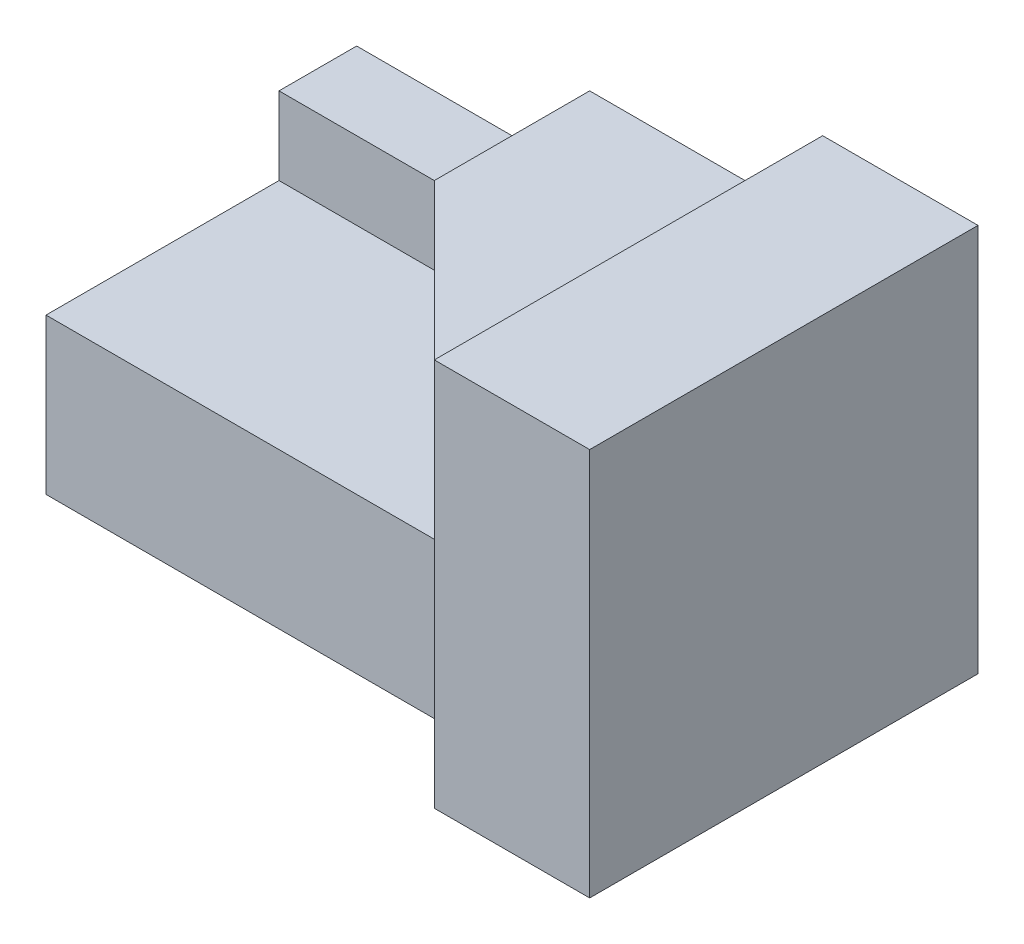
from build123d import *

# Parameters (mm, degrees)
SKETCH1_W           = 80
SKETCH1_H           = 50
BOSS_EXTRUDE2_DEPTH = 50
SKETCH2_W           = 60
SKETCH2_H           = 10
CUT_EXTRUDE1_DEPTH  = 50
SKETCH3_W           = 30
SKETCH3_H           = 10
CUT_EXTRUDE2_DEPTH  = 50
CUT_EXTRUDE3_DEPTH  = 50
CUT_EXTRUDE4_DEPTH  = 20
CUT_EXTRUDE5_DEPTH  = 10


with BuildPart() as part:
    # Sketch1 → Boss-Extrude2 (new body)
    with BuildSketch(Plane.XY):
        with Locations((40, 25)):
            Rectangle(SKETCH1_W, SKETCH1_H)
    extrude(amount=-BOSS_EXTRUDE2_DEPTH)

    # Sketch2 → Cut-Extrude1 (cut)
    with BuildSketch(Plane.XY):
        with Locations((30, 45)):
            Rectangle(SKETCH2_W, SKETCH2_H)
    extrude(amount=-CUT_EXTRUDE1_DEPTH, mode=Mode.SUBTRACT)

    # Sketch3 → Cut-Extrude2 (cut)
    with BuildSketch(Plane.XY):
        with Locations((15, 35)):
            Rectangle(SKETCH3_W, SKETCH3_H)
    extrude(amount=-CUT_EXTRUDE2_DEPTH, mode=Mode.SUBTRACT)

    # Sketch4 → Cut-Extrude3 (cut)
    with BuildSketch(Plane.XZ):
        Polygon((60, 0), (0, 0), (0, -10), (50, -10), align=None)
    extrude(amount=-CUT_EXTRUDE3_DEPTH, mode=Mode.SUBTRACT)

    # Sketch5 → Cut-Extrude4 (cut)
    with BuildSketch(Plane(origin=(0, 40, 0), x_dir=(1, 0, 0), z_dir=(0, 1, 0))):
        Polygon((50, 10), (30, 30), (30, 10), align=None)
    extrude(amount=-CUT_EXTRUDE4_DEPTH, mode=Mode.SUBTRACT)

    # Sketch6 → Cut-Extrude5 (cut)
    with BuildSketch(Plane(origin=(0, 30, 0), x_dir=(1, 0, 0), z_dir=(0, 1, 0))):
        Polygon((0, 10), (50, 10), (20, 40), (0, 40), align=None)
    extrude(amount=-CUT_EXTRUDE5_DEPTH, mode=Mode.SUBTRACT)


solid = part.part
